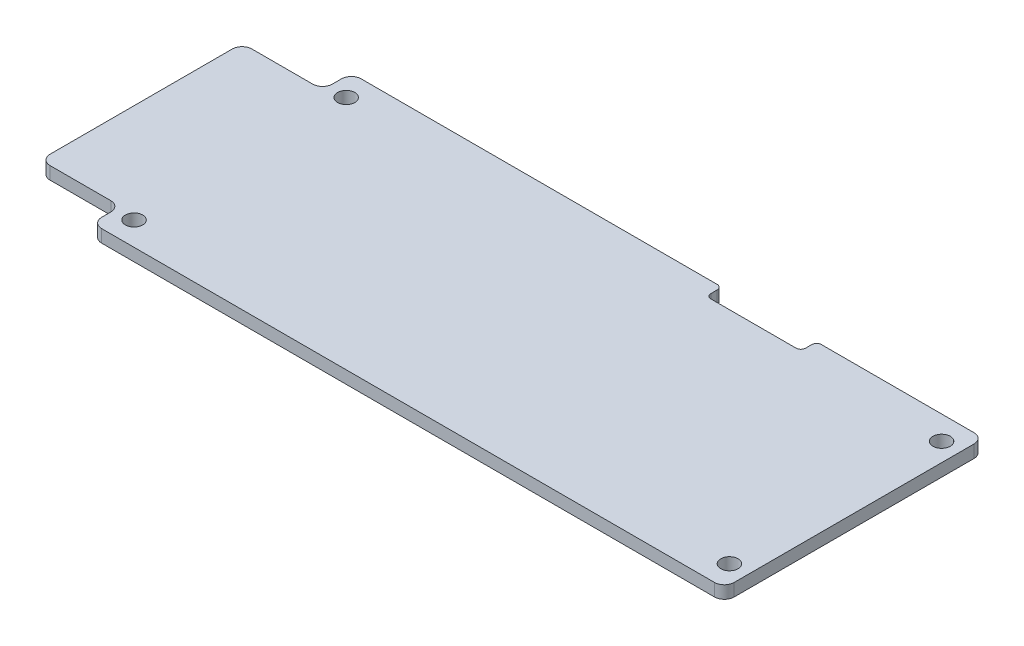
from build123d import *

# Parameters (mm, degrees)
SKETCH_1_R      = 1.1
EXTRUDE_1_DEPTH = 1.6


with BuildPart() as part:
    # 草图1 → 凸台-拉伸1 (new body)
    with BuildSketch(Plane(origin=(0, 0, 0), x_dir=(1, 0, 0), z_dir=(0, 1, 0))):
        with BuildLine():
            ThreePointArc((0, 1.25), (0.366116524, 0.366116524), (1.25, 0))
            Line((1.25, 0), (78.95, 0))
            ThreePointArc((78.95, 0), (79.833883476, 0.366116524), (80.2, 1.25))
            Line((80.2, 1.25), (80.2, 31.65))
            ThreePointArc((80.2, 31.65), (79.833883476, 32.533883476), (78.95, 32.9))
            Line((78.95, 32.9), (59.6, 32.9))
            ThreePointArc((59.6, 32.9), (59.175735931, 32.724264069), (59, 32.3))
            Line((59, 32.3), (59, 31.5))
            ThreePointArc((59, 31.5), (58.824264069, 31.075735931), (58.4, 30.9))
            Line((58.4, 30.9), (47.6, 30.9))
            ThreePointArc((47.6, 30.9), (47.175735931, 31.075735931), (47, 31.5))
            Line((47, 31.5), (47, 32.3))
            ThreePointArc((47, 32.3), (46.824264069, 32.724264069), (46.4, 32.9))
            Line((46.4, 32.9), (1.25, 32.9))
            ThreePointArc((1.25, 32.9), (0.366116524, 32.533883476), (0, 31.65))
            Line((0, 31.65), (0, 30.5))
            ThreePointArc((0, 30.5), (-0.366116524, 29.616116524), (-1.25, 29.25))
            Line((-1.25, 29.25), (-8.95, 29.25))
            ThreePointArc((-8.95, 29.25), (-9.833883476, 28.883883476), (-10.2, 28))
            Line((-10.2, 28), (-10.2, 4.9))
            ThreePointArc((-10.2, 4.9), (-9.833883476, 4.016116524), (-8.95, 3.65))
            Line((-8.95, 3.65), (-1.25, 3.65))
            ThreePointArc((-1.25, 3.65), (-0.366116524, 3.283883476), (0, 2.4))
            Line((0, 2.4), (0, 1.25))
        make_face()
        with Locations((2.35, 3)):
            Circle(SKETCH_1_R, mode=Mode.SUBTRACT)
        with Locations((77.85, 3)):
            Circle(SKETCH_1_R, mode=Mode.SUBTRACT)
        with Locations((2.35, 29.9)):
            Circle(SKETCH_1_R, mode=Mode.SUBTRACT)
        with Locations((77.85, 29.9)):
            Circle(SKETCH_1_R, mode=Mode.SUBTRACT)
    extrude(amount=EXTRUDE_1_DEPTH)


solid = part.part
